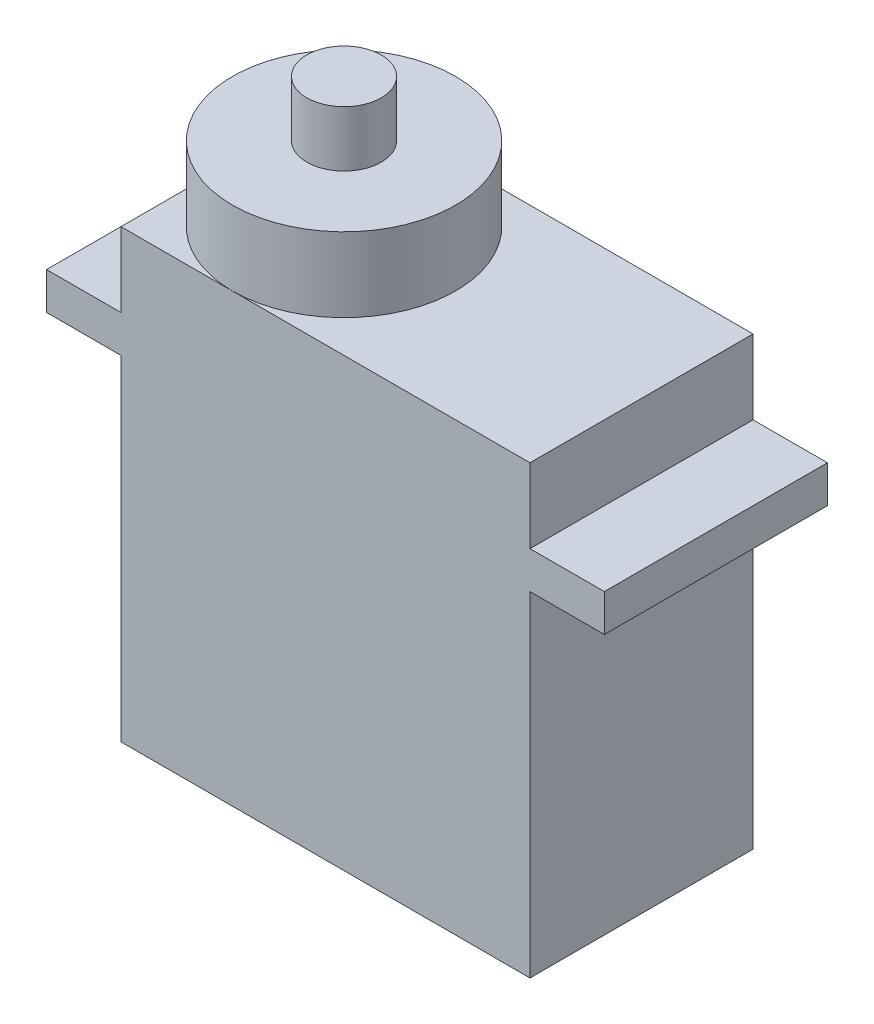
from build123d import *

# Parameters (mm, degrees)
SKETCH1_W           = 22
SKETCH1_H           = 24
BOSS_EXTRUDE1_DEPTH = 12
BOSS_EXTRUDE2_START = 4
SKETCH2_W           = 12
SKETCH2_H           = 2
BOSS_EXTRUDE2_DEPTH = 30
SKETCH3_R           = 6
BOSS_EXTRUDE3_DEPTH = 4
SKETCH4_R           = 2
BOSS_EXTRUDE4_DEPTH = 3


with BuildPart() as part:
    # Sketch1 → Boss-Extrude1 (new body)
    with BuildSketch(Plane.XY):
        Rectangle(SKETCH1_W, SKETCH1_H)
    extrude(amount=BOSS_EXTRUDE1_DEPTH)

    # Sketch2 → Boss-Extrude2 (add)
    with BuildSketch(Plane.ZY.offset(11).offset(BOSS_EXTRUDE2_START)):
        with Locations((6, 7)):
            Rectangle(SKETCH2_W, SKETCH2_H)
    extrude(amount=-BOSS_EXTRUDE2_DEPTH)

    # Sketch3 → Boss-Extrude3 (add)
    with BuildSketch(Plane(origin=(0, 12, 0), x_dir=(1, 0, 0), z_dir=(0, 1, 0))):
        with Locations((-5, -6)):
            Circle(SKETCH3_R)
    extrude(amount=BOSS_EXTRUDE3_DEPTH)

    # Sketch4 → Boss-Extrude4 (add)
    with BuildSketch(Plane(origin=(0, 16, 0), x_dir=(1, 0, 0), z_dir=(0, 1, 0))):
        with Locations((-5, -6)):
            Circle(SKETCH4_R)
    extrude(amount=BOSS_EXTRUDE4_DEPTH)


solid = part.part
